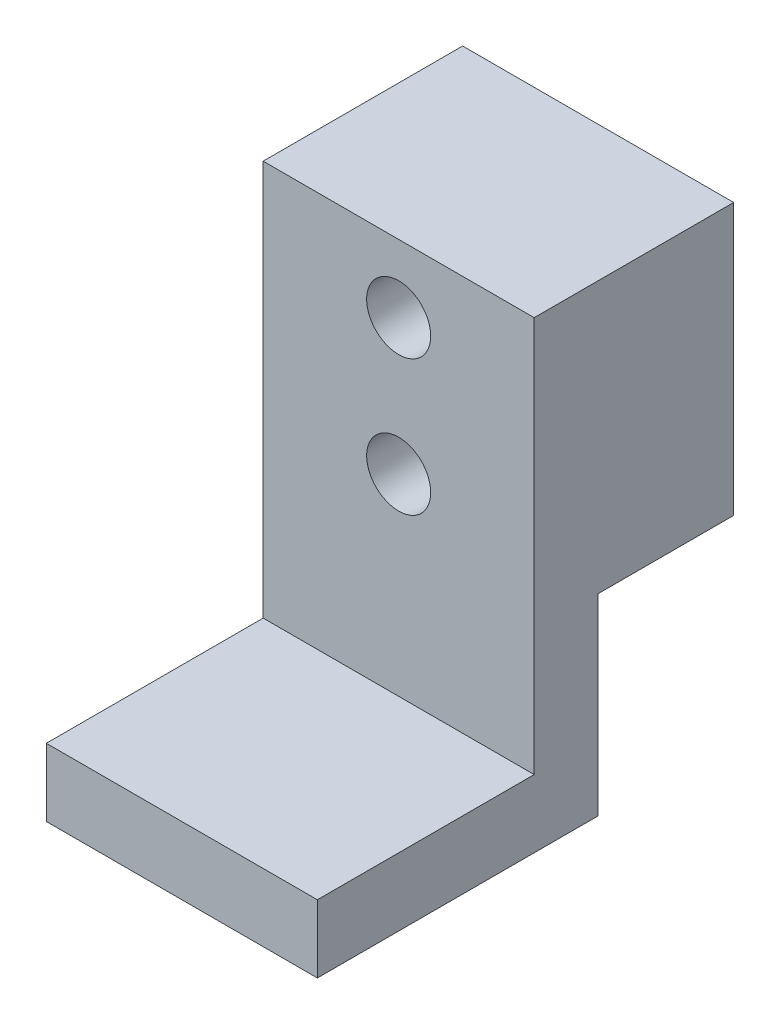
from build123d import *

# Parameters (mm, degrees)
BOSS_EXTRUDE1_DEPTH = 6.35
SKETCH2_R           = 1.5
CUT_EXTRUDE1_DEPTH  = 10.3472


with BuildPart() as part:
    # Sketch1 → Boss-Extrude1 (new body, symmetric)
    with BuildSketch(Plane(origin=(0, 0, 0), x_dir=(0, 0, -1), z_dir=(1, 0, 0))):
        Polygon((0, 12.7), (0, 0), (-6.35, 0), (-6.35, -9.017), (-19.5072, -9.017), (-19.5072, -5.842), (-9.3472, -5.842), (-9.3472, 12.7), align=None)
    extrude(amount=BOSS_EXTRUDE1_DEPTH, both=True)

    # Sketch2 → Cut-Extrude1 (cut, through all)
    with BuildSketch(Plane.XY.offset(9.3472)):
        with Locations((0, 9.525)):
            Circle(SKETCH2_R)
        with Locations((0, 3.175)):
            Circle(SKETCH2_R)
    extrude(amount=-CUT_EXTRUDE1_DEPTH, mode=Mode.SUBTRACT)


solid = part.part
